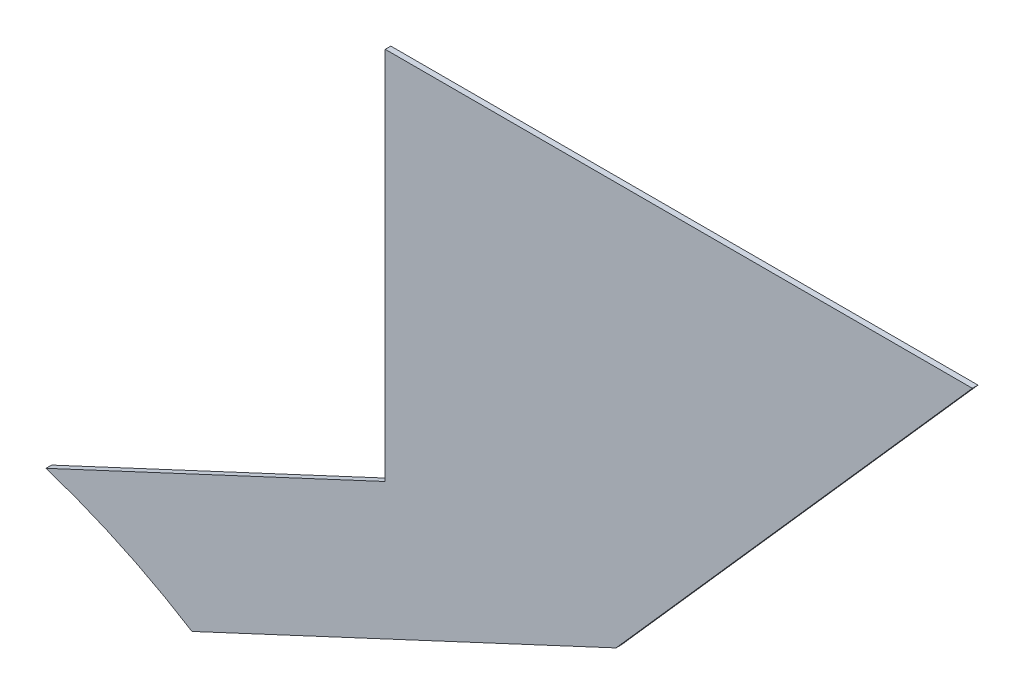
from build123d import *

# Parameters (mm, degrees)
BOSS_EXTRUDE1_DEPTH = 1.51892


with BuildPart() as part:
    # Sketch1 → Boss-Extrude1 (new body)
    with BuildSketch(Plane.XY):
        with BuildLine():
            Line((55.63108, 170.471282062), (147.711951163, 213.409297455))
            Line((147.711951163, 213.409297455), (147.711951163, 315.009297455))
            Line((147.711951163, 315.009297455), (307.102060534, 315.009297455))
            Line((307.102060534, 315.009297455), (210.351088954, 205.602478663))
            Line((210.351088954, 205.602478663), (95.25, 151.929959422))
            ThreePointArc((95.25, 151.929959422), (76.00802745, 162.41322247), (55.63108, 170.471282062))
        make_face()
    extrude(amount=BOSS_EXTRUDE1_DEPTH)


solid = part.part
